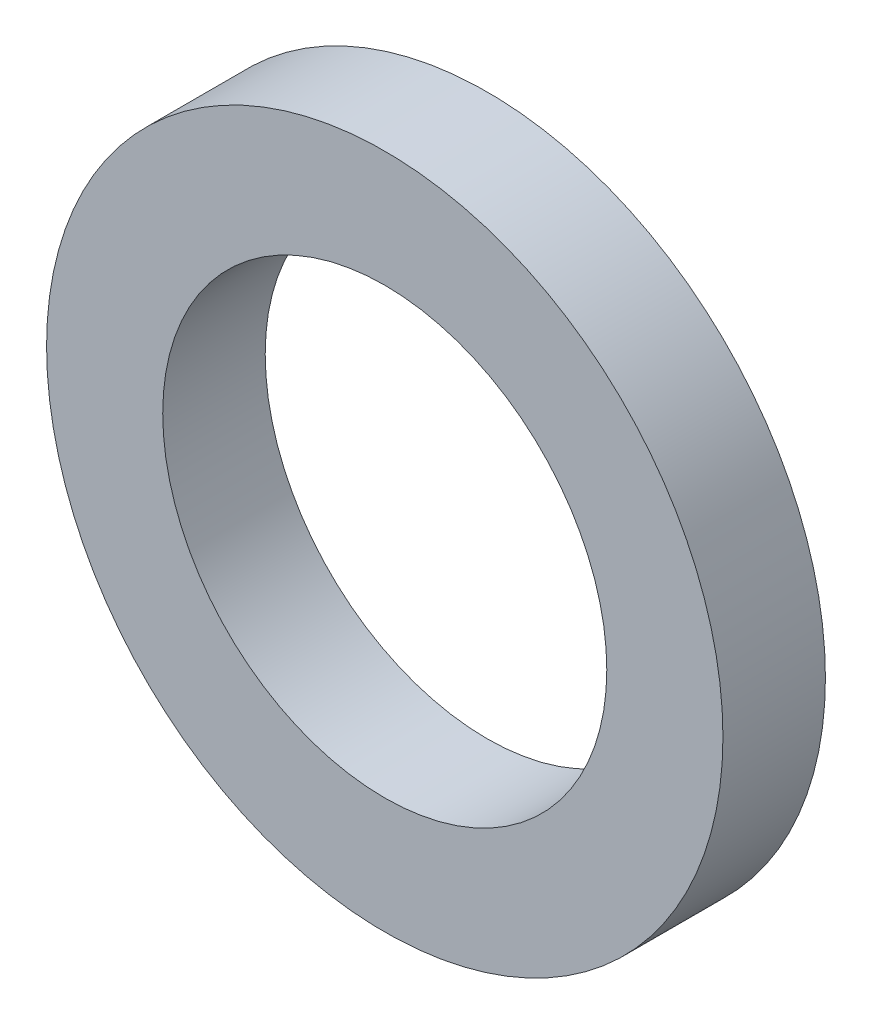
from build123d import *

# Parameters (mm, degrees)
SKETCH1_R           = 4.95
SKETCH1_R_2         = 3.25
BOSS_EXTRUDE1_DEPTH = 1.5


with BuildPart() as part:
    # Sketch1 → Boss-Extrude1 (new body)
    with BuildSketch(Plane.XY):
        Circle(SKETCH1_R)
        Circle(SKETCH1_R_2, mode=Mode.SUBTRACT)
    extrude(amount=BOSS_EXTRUDE1_DEPTH)


solid = part.part
